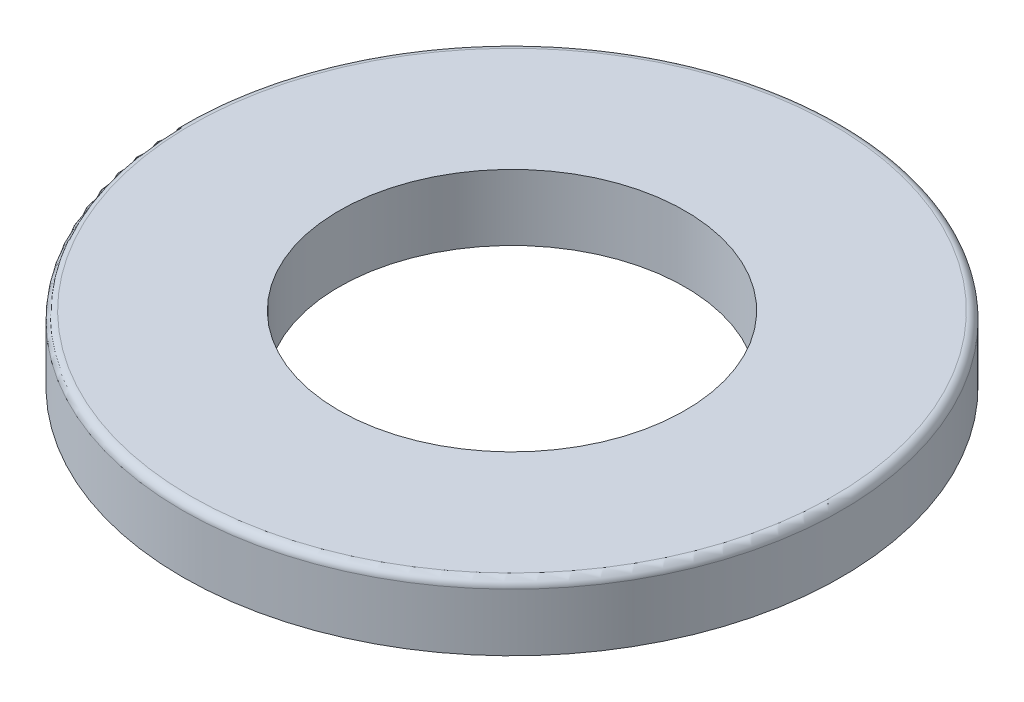
from build123d import *

# Parameters (mm, degrees)
SKETCH1_R           = 8
SKETCH1_R_2         = 4.2
BOSS_EXTRUDE1_DEPTH = 1.6
FILLET1_R           = 0.2


with BuildPart() as part:
    # Sketch1 → Boss-Extrude1 (new body)
    with BuildSketch(Plane(origin=(0, 0, 0), x_dir=(1, 0, 0), z_dir=(0, 1, 0))):
        Circle(SKETCH1_R)
        Circle(SKETCH1_R_2, mode=Mode.SUBTRACT)
    extrude(amount=BOSS_EXTRUDE1_DEPTH)

    # Fillet1
    fillet1_edges = [part.edges().sort_by_distance(p)[0] for p in [
        (-8, 1.6, 0),
    ]]
    fillet(fillet1_edges, radius=FILLET1_R)


solid = part.part
